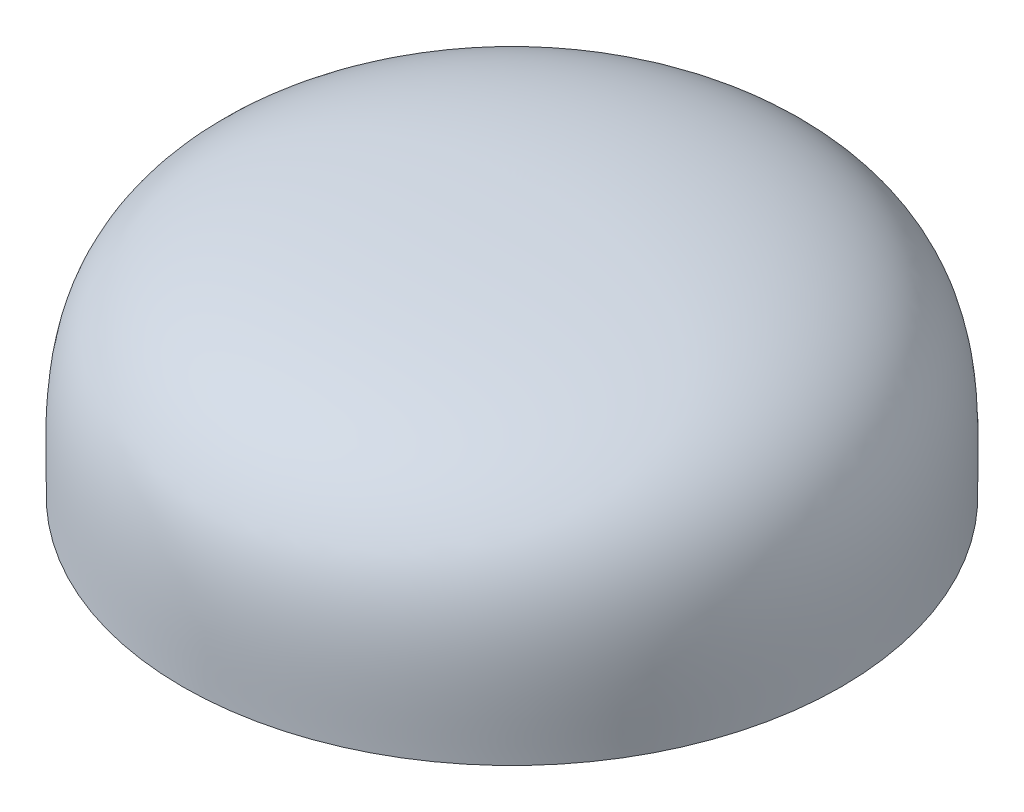
from build123d import *


with BuildPart() as part:
    # Sketch1 → Revolve1 (revolve)
    with BuildSketch(Plane.XY):
        with BuildLine():
            Line((-1.5, 0), (-6.5, 0))
            add(Edge.make_bspline(
                [(0, 5), (-6.963785829, 5), (-6.5, 2.459448899), (-6.5, 0)],
                knots=[0, 0, 0, 0, 1, 1, 1, 1], degree=3))
            Line((0, 5), (0, 3))
            Line((0, 3), (-1.5, 3))
            Line((-1.5, 3), (-1.5, 0))
        make_face()
    revolve(axis=Axis((0, 3, 0), (0, 1, 0)))


solid = part.part
